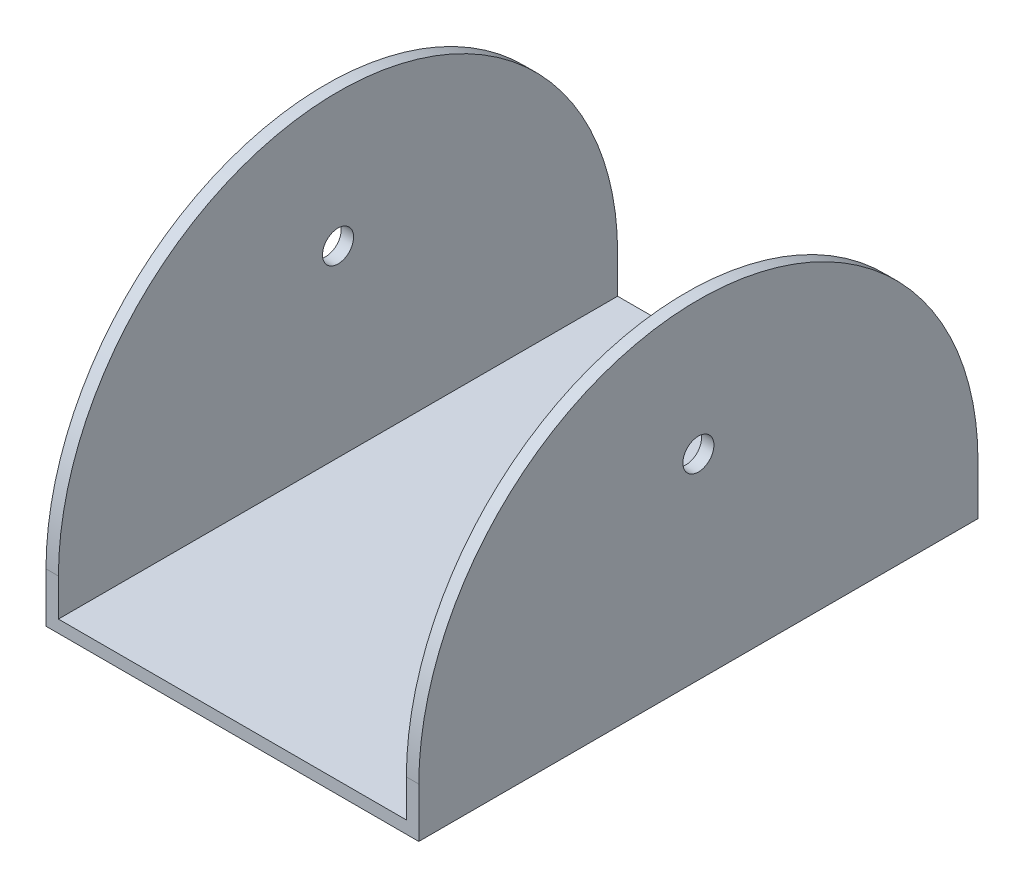
from build123d import *

# Parameters (mm, degrees)
EXTRUDE_1_DEPTH      = 45
EXTRUDE_1_DEPTH_BACK = 45
CUT_EXTRUDE_1_DEPTH  = 90.053829869
SKETCH_4_R           = 2.5
CUT_EXTRUDE_2_DEPTH  = 90.053829869
SKETCH_5_R           = 4
CUT_EXTRUDE_3_DEPTH  = 50


with BuildPart() as part:
    # 草图1 → 凸台-拉伸1 (new, two sides: drawn at the far end of the back side and taken through both)
    with BuildSketch(Plane.XY.offset(-EXTRUDE_1_DEPTH_BACK)):
        Polygon((30, -4.983496438), (-30, -4.983496438), (-30, 48.016503562), (-28, 48.016503562), (-28, -2.983496438), (28, -2.983496438), (28, 48.016503562), (30, 48.016503562), align=None)
    extrude(amount=EXTRUDE_1_DEPTH + EXTRUDE_1_DEPTH_BACK)

    # 草图3 → 切除-拉伸1 (cut, through all)
    with BuildSketch(Plane(origin=(30, 0, 0), x_dir=(0, 0, -1), z_dir=(1, 0, 0))):
        with BuildLine():
            Line((45, 48.016503562), (9.2e-08, 48.016503562))
            ThreePointArc((9.2e-08, 48.016503562), (31.819805186, 34.836308683), (45, 3.016503562))
            Line((45, 3.016503562), (45, 48.016503562))
        make_face()
        with BuildLine():
            Line((-45, 48.016503562), (-45, 3.016503562))
            ThreePointArc((-45, 3.016503562), (-31.819805121, 34.836308748), (9.2e-08, 48.016503562))
            Line((9.2e-08, 48.016503562), (-45, 48.016503562))
        make_face()
    extrude(amount=-CUT_EXTRUDE_1_DEPTH, mode=Mode.SUBTRACT)

    # 草图4 → 切除-拉伸2 (cut, through all)
    with BuildSketch(Plane.ZY.offset(30)):
        with Locations((0, 26.516503562)):
            Circle(SKETCH_4_R)
    extrude(amount=-CUT_EXTRUDE_2_DEPTH, mode=Mode.SUBTRACT)

    # 草图5 → 切除-拉伸3 (cut)
    with BuildSketch(Plane.XZ.offset(4.983496438)):
        Circle(SKETCH_5_R)
    extrude(amount=-CUT_EXTRUDE_3_DEPTH, mode=Mode.SUBTRACT)


solid = part.part
